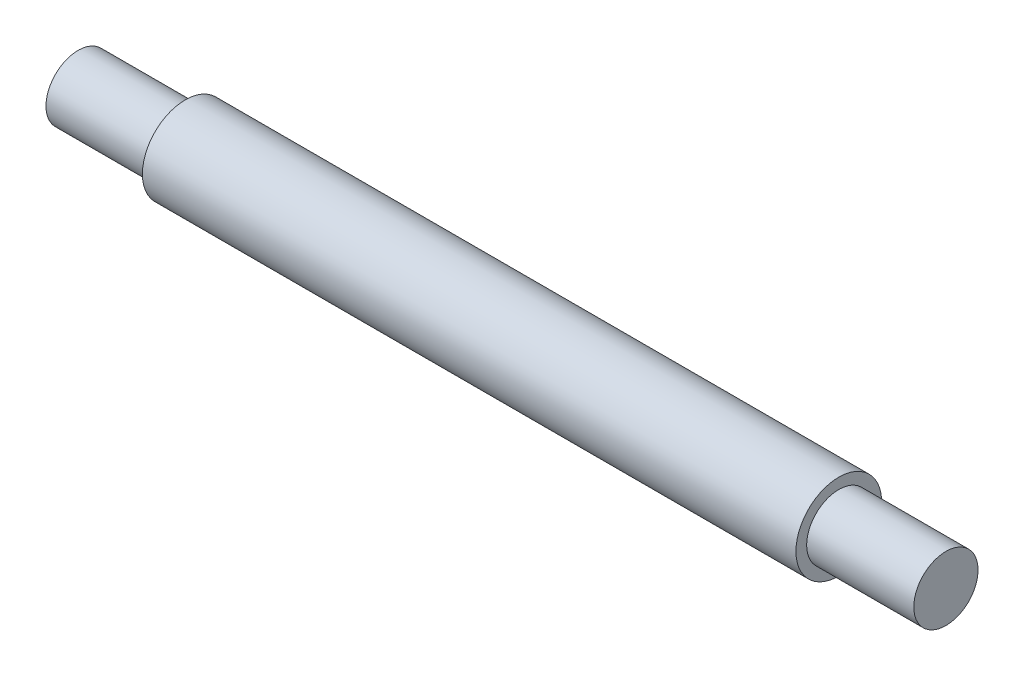
from build123d import *


with BuildPart() as part:
    # 草图1 → 旋转1 (revolve)
    with BuildSketch(Plane.XY):
        Polygon((-40.5, 0), (40.5, 0), (40.5, 3), (30.5, 3), (30.5, 4), (-30.5, 4), (-30.5, 3), (-40.5, 3), align=None)
    revolve(axis=Axis((-73.230964467, 0, 0), (1, 0, 0)))


solid = part.part
